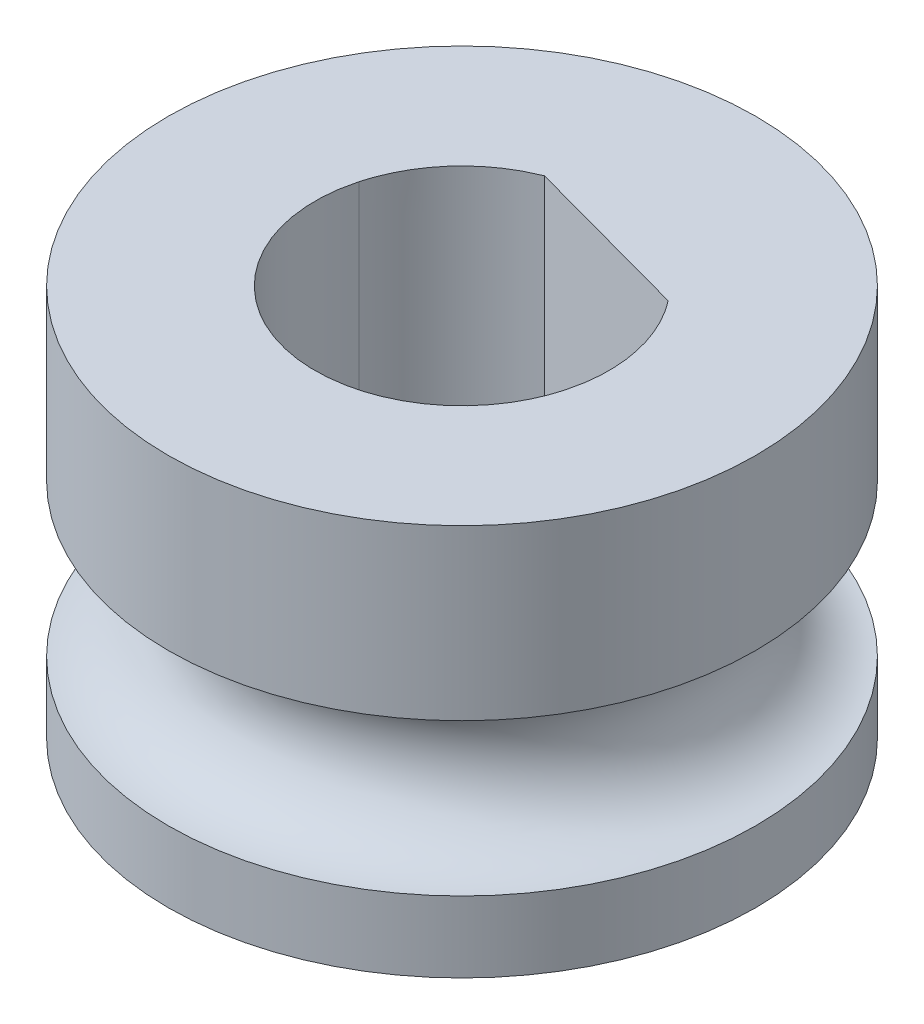
from build123d import *

# Parameters (mm, degrees)
SKETCH1_R           = 6
BOSS_EXTRUDE1_DEPTH = 8
SKETCH2_R           = 1.55
CUT_EXTRUDE1_DEPTH  = 8


with BuildPart() as part:
    # Sketch1 → Boss-Extrude1 (new body)
    with BuildSketch(Plane(origin=(0, 0, 0), x_dir=(1, 0, 0), z_dir=(0, 1, 0))):
        Circle(SKETCH1_R)
    extrude(amount=BOSS_EXTRUDE1_DEPTH)

    # Sketch2 → Cut-Revolve1 (revolve, cut)
    with BuildSketch(Plane.XY):
        with Locations((6, 3)):
            Circle(SKETCH2_R)
    revolve(axis=Axis((0, 0, 0), (0, 1, 0)), mode=Mode.SUBTRACT)

    # Sketch4 → Cut-Extrude1 (cut)
    with BuildSketch(Plane(origin=(0, 8, 0), x_dir=(1, 0, 0), z_dir=(0, 1, 0))):
        with BuildLine():
            Line((2.367842107, 1.842094434), (-1.105416324, 2.788918537))
            add(Edge.make_bspline(
                [(-1.105416324, 2.788918537), (-1.211764888, 2.742631763), (-1.424454479, 2.650061493), (-1.720250186, 2.465348), (-1.994235491, 2.250550124), (-2.240915768, 2.004518267), (-2.457887126, 1.732083649), (-2.610986563, 1.48525109), (-2.715877402, 1.278481127), (-2.78522539, 1.119080225), (-2.845851316, 0.956099515), (-2.87818707, 0.844775171), (-2.894381942, 0.789020063)],
                knots=[0, 0, 0, 0, 0.124991315, 0.249973772, 0.374969516, 0.499947485, 0.624943228, 0.749921197, 0.812549698, 0.874965023, 0.93737813, 1, 1, 1, 1], degree=3))
            add(Edge.make_bspline(
                [(-2.894381942, 0.789020063), (-2.91771894, 0.693111264), (-2.96416552, 0.502228293), (-2.997819256, 0.209481258), (-3.004051012, -0.084817673), (-2.972979949, -0.476455315), (-2.864367877, -0.958570493), (-2.620857625, -1.498032442), (-2.279511198, -1.981666548), (-1.848081992, -2.386982606), (-1.347643479, -2.703146387), (-0.793946169, -2.912516199), (-0.21061126, -3.013102534), (0.381062278, -2.994642374), (0.958480559, -2.864348225), (1.498072184, -2.620836257), (1.981597519, -2.279616329), (2.29100443, -1.950138678), (2.473270872, -1.700917619), (2.56507701, -1.55952933), (2.648325999, -1.413887775), (2.723092545, -1.264002096), (2.789155439, -1.109821709), (2.84731552, -0.951568689), (2.878651893, -0.84334537), (2.894381942, -0.789020063)],
                knots=[0, 0, 0, 0, 0.031431158, 0.06255602, 0.093680213, 0.125109383, 0.187591007, 0.250067296, 0.312548923, 0.37502521, 0.437506837, 0.499983124, 0.562464749, 0.624941037, 0.687422663, 0.749898951, 0.812380576, 0.874856864, 0.892877316, 0.910755613, 0.928547986, 0.946311478, 0.964103414, 0.981980842, 1, 1, 1, 1], degree=3))
            add(Edge.make_bspline(
                [(2.894381942, -0.789020063), (2.921161696, -0.676169025), (2.974719306, -0.450474947), (3.004425987, -0.103009906), (2.996978881, 0.245057447), (2.94816153, 0.590021165), (2.860396577, 0.9270594), (2.754790092, 1.197638787), (2.652308524, 1.405613669), (2.566396509, 1.55673277), (2.472387401, 1.703022102), (2.402729306, 1.795685419), (2.367842107, 1.842094434)],
                knots=[0, 0, 0, 0, 0.124991314, 0.249973772, 0.374969515, 0.499947485, 0.624943228, 0.749921198, 0.812549697, 0.874965022, 0.937378129, 1, 1, 1, 1], degree=3))
        make_face()
    extrude(amount=-CUT_EXTRUDE1_DEPTH, mode=Mode.SUBTRACT)


solid = part.part
